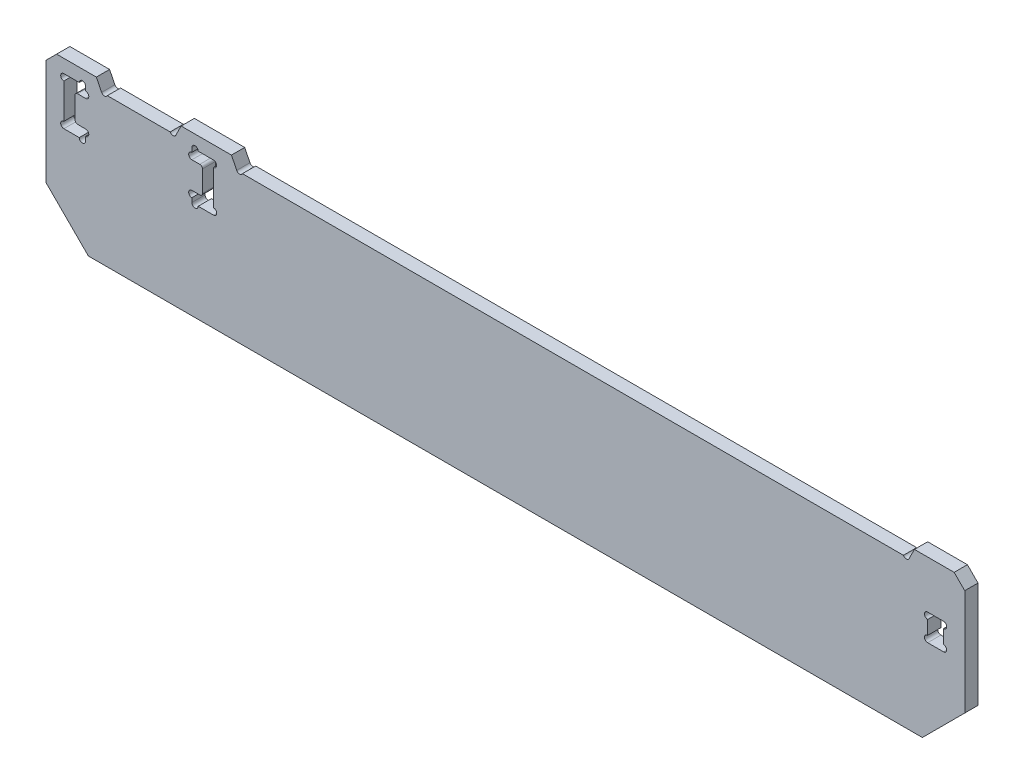
from build123d import *

# Parameters (mm, degrees)
SKETCH_1_W          = 173.4
SKETCH_1_H          = 30
EXTRUDE_1_DEPTH     = 1.25
CHAMFER_1_SIZE      = 8
CHAMFER_2_SIZE      = 2
CUT_EXTRUDE_1_DEPTH = 3.5
CUT_EXTRUDE_4_DEPTH = 3.5
CUT_EXTRUDE_2_DEPTH = 3.5
SKETCH_5_R          = 0.6
CUT_EXTRUDE_3_DEPTH = 3.5
FILLET_1_R          = 0.5
SKETCH_7_W          = 3
SKETCH_7_H          = 5
CUT_EXTRUDE_5_DEPTH = 3.5
SKETCH_8_R          = 0.6
CUT_EXTRUDE_6_DEPTH = 3.5


with BuildPart() as part:
    # 草图1 → 凸台-拉伸1 (new body, symmetric)
    with BuildSketch(Plane.XY):
        with Locations((0, -15)):
            Rectangle(SKETCH_1_W, SKETCH_1_H)
    extrude(amount=EXTRUDE_1_DEPTH, both=True)

    # 倒角1
    chamfer_1_edges = [part.edges().sort_by_distance(p)[0] for p in [
        (86.7, -30, 0),
        (-86.7, -30, 0),
    ]]
    chamfer(chamfer_1_edges, length=CHAMFER_1_SIZE)

    # 倒角2
    chamfer_2_edges = [part.edges().sort_by_distance(p)[0] for p in [
        (-86.7, 0, 0),
        (86.7, 0, 0),
    ]]
    chamfer(chamfer_2_edges, length=CHAMFER_2_SIZE)

    # 草图2 → 切除-拉伸1 (cut, through all)
    with BuildSketch(Plane.XY.offset(1.25)):
        Polygon((-77.2, 0), (-76.2, -2), (-62.2, -2), (-61.2, 0), align=None)
    extrude(amount=-CUT_EXTRUDE_1_DEPTH, mode=Mode.SUBTRACT)

    # 草图6 → 切除-拉伸4 (cut, through all)
    with BuildSketch(Plane.XY.offset(1.25)):
        Polygon((-51.7, 0), (-50.7, -2), (76.2, -2), (77.2, 0), align=None)
    extrude(amount=-CUT_EXTRUDE_4_DEPTH, mode=Mode.SUBTRACT)

    # 草图4 → 切除-拉伸2 (cut, through all)
    with BuildSketch(Plane.XY.offset(1.25)):
        Polygon((-83.325, -2.5), (-79.225, -2.5), (-79.225, -4.5), (-81.225, -4.5), (-81.225, -9.5), (-79.225, -9.5), (-79.225, -11.5), (-83.325, -11.5), align=None)
        Polygon((-59.175, -11.5), (-55.075, -11.5), (-55.075, -2.5), (-59.175, -2.5), (-59.175, -4.5), (-57.175, -4.5), (-57.175, -9.5), (-59.175, -9.5), align=None)
    extrude(amount=-CUT_EXTRUDE_2_DEPTH, mode=Mode.SUBTRACT)

    # 草图5 → 切除-拉伸3 (cut, through all)
    with BuildSketch(Plane.XY.offset(1.25)):
        with Locations((-83.325, -3.1)):
            Circle(SKETCH_5_R)
        with Locations((-83.325, -10.9)):
            Circle(SKETCH_5_R)
        with Locations((-79.825, -11.5)):
            Circle(SKETCH_5_R)
        with Locations((-79.225, -10.1)):
            Circle(SKETCH_5_R)
        with Locations((-79.225, -3.9)):
            Circle(SKETCH_5_R)
        with Locations((-79.825, -2.5)):
            Circle(SKETCH_5_R)
        with Locations((-58.575, -2.5)):
            Circle(SKETCH_5_R)
        with Locations((-59.175, -3.9)):
            Circle(SKETCH_5_R)
        with Locations((-59.175, -10.1)):
            Circle(SKETCH_5_R)
        with Locations((-58.575, -11.5)):
            Circle(SKETCH_5_R)
        with Locations((-55.075, -10.9)):
            Circle(SKETCH_5_R)
        with Locations((-55.075, -3.1)):
            Circle(SKETCH_5_R)
        with Locations((-75.663343685, -1.731671843)):
            Circle(SKETCH_5_R)
        with Locations((-62.736656315, -1.731671843)):
            Circle(SKETCH_5_R)
        with Locations((-50.163343685, -1.731671843)):
            Circle(SKETCH_5_R)
        with Locations((75.663343685, -1.731671843)):
            Circle(SKETCH_5_R)
    extrude(amount=-CUT_EXTRUDE_3_DEPTH, mode=Mode.SUBTRACT)

    # 圆角1
    fillet_1_edges = [part.edges().sort_by_distance(p)[0] for p in [
        (-57.175, -9.5, 0),
        (-57.175, -4.5, 0),
        (-81.225, -4.5, 0),
        (-81.225, -9.5, 0),
    ]]
    fillet(fillet_1_edges, radius=FILLET_1_R)

    # 草图7 → 切除-拉伸5 (cut, through all)
    with BuildSketch(Plane.XY.offset(1.25)):
        with Locations((81.2, -11.5)):
            Rectangle(SKETCH_7_W, SKETCH_7_H)
    extrude(amount=-CUT_EXTRUDE_5_DEPTH, mode=Mode.SUBTRACT)

    # 草图8 → 切除-拉伸6 (cut, through all)
    with BuildSketch(Plane.XY.offset(1.25)):
        with Locations((79.7, -9.6)):
            Circle(SKETCH_8_R)
        with Locations((79.7, -13.4)):
            Circle(SKETCH_8_R)
        with Locations((82.7, -13.4)):
            Circle(SKETCH_8_R)
        with Locations((82.7, -9.6)):
            Circle(SKETCH_8_R)
    extrude(amount=-CUT_EXTRUDE_6_DEPTH, mode=Mode.SUBTRACT)


solid = part.part
